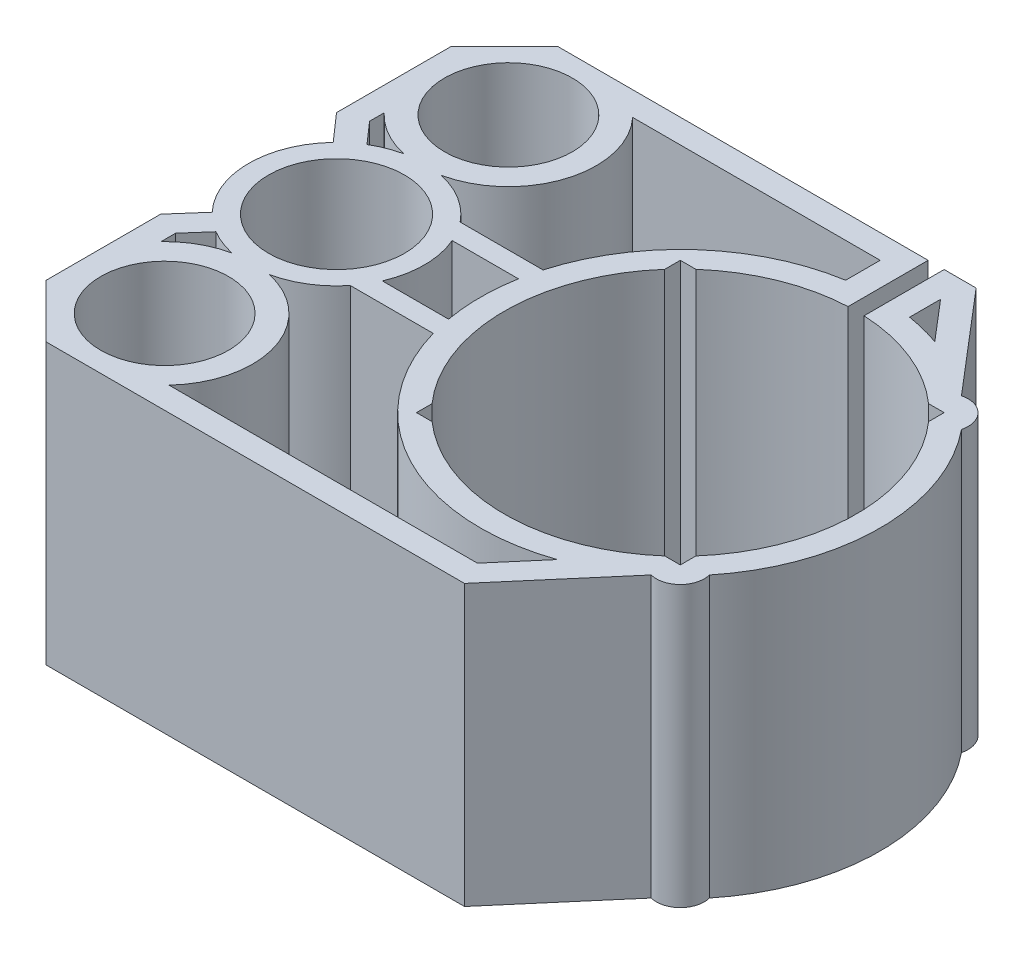
from build123d import *

# Parameters (mm, degrees)
SKETCH1_R           = 8
SKETCH1_R_2         = 8.5
BOSS_EXTRUDE1_DEPTH = 35
BOSS_EXTRUDE3_DEPTH = 12
CUT_EXTRUDE1_DEPTH  = 14.407172
SKETCH7_R           = 8.5
BOSS_EXTRUDE4_DEPTH = 15
SKETCH7_3_R         = 5
CUT_EXTRUDE2_DEPTH  = 15
SKETCH7_4_R         = 6.165
CUT_EXTRUDE3_DEPTH  = 1.5
SKETCH7_5_R         = 1.425
CUT_EXTRUDE4_DEPTH  = 8


with BuildPart() as part:
    # Sketch1 → Boss-Extrude1 (new body)
    with BuildSketch(Plane(origin=(0, 0, 0), x_dir=(1, 0, 0), z_dir=(0, 1, 0))):
        with BuildLine():
            ThreePointArc((-50.982546594, 7.568285795), (-54, 0), (-50.982546594, -7.568285795))
            Line((-50.982546594, -7.568285795), (-54, -11))
            Line((-54, -11), (-54, -25.34082208))
            Line((-54, -25.34082208), (-47.34082208, -32))
            Line((-47.34082208, -32), (5, -32))
            Line((5, -32), (15.759494281, -19.407172386))
            ThreePointArc((15.759494281, -19.407172386), (18.621320344, -18.621320344), (19.407172386, -15.759494281))
            ThreePointArc((19.407172386, -15.759494281), (25, 0), (19.407172386, 15.759494281))
            ThreePointArc((19.407172386, 15.759494281), (18.621320344, 18.621320344), (15.759494281, 19.407172386))
            Line((15.759494281, 19.407172386), (5, 32))
            Line((5, 32), (1, 32))
            Line((1, 32), (1, 21.977260976))
            ThreePointArc((1, 21.977260976), (8.243992543, 20.396974946), (14.551632211, 16.5))
            Line((14.551632211, 16.5), (16.5, 16.5))
            Line((16.5, 16.5), (16.5, 14.551632211))
            ThreePointArc((16.5, 14.551632211), (22, 0), (16.5, -14.551632211))
            Line((16.5, -14.551632211), (16.5, -16.5))
            Line((16.5, -16.5), (14.551632211, -16.5))
            ThreePointArc((14.551632211, -16.5), (0, -22), (-14.551632211, -16.5))
            Line((-14.551632211, -16.5), (-16.5, -16.5))
            Line((-16.5, -16.5), (-16.5, -14.551632211))
            ThreePointArc((-16.5, -14.551632211), (-22, 0), (-16.5, 14.551632211))
            Line((-16.5, 14.551632211), (-16.5, 16.5))
            Line((-16.5, 16.5), (-14.551632211, 16.5))
            ThreePointArc((-14.551632211, 16.5), (-8.243992543, 20.396974946), (-1, 21.977260976))
            Line((-1, 21.977260976), (-1, 32))
            Line((-1, 32), (-47.34082208, 32))
            Line((-47.34082208, 32), (-54, 25.34082208))
            Line((-54, 25.34082208), (-54, 11))
            Line((-54, 11), (-50.982546594, 7.568285795))
        make_face()
        with BuildLine():
            ThreePointArc((-48.638105805, -9.445197877), (-47.038026147, -10.232025451), (-45.331844763, -10.75))
            ThreePointArc((-45.331844763, -10.75), (-48.408051309, -11.921222362), (-51, -13.950165565))
            Line((-51, -13.950165565), (-51, -12.131352314))
            Line((-51, -12.131352314), (-48.638105805, -9.445197877))
        make_face(mode=Mode.SUBTRACT)
        with Locations((-43, -21.5)):
            Circle(SKETCH1_R, mode=Mode.SUBTRACT)
        with BuildLine():
            ThreePointArc((-34.95326153, -29), (-32.502649264, -18.212808567), (-40.668155237, -10.75))
            ThreePointArc((-40.668155237, -10.75), (-37.204464997, -9.349426401), (-34.409357086, -6.870287791))
            Line((-34.409357086, -6.870287791), (-24.037452978, -6.870287791))
            ThreePointArc((-24.037452978, -6.870287791), (-11.513133706, -22.191163833), (8.224630177, -23.60837687))
            Line((8.224630177, -23.60837687), (3.617949295, -29))
            Line((3.617949295, -29), (-34.95326153, -29))
        make_face(mode=Mode.SUBTRACT)
        with Locations((-43, 0)):
            Circle(SKETCH1_R_2, mode=Mode.SUBTRACT)
        with BuildLine():
            ThreePointArc((-45.331844763, 10.75), (-47.038026147, 10.232025451), (-48.638105805, 9.445197877))
            Line((-48.638105805, 9.445197877), (-51, 12.131352314))
            Line((-51, 12.131352314), (-51, 13.950165565))
            ThreePointArc((-51, 13.950165565), (-48.408051309, 11.921222362), (-45.331844763, 10.75))
        make_face(mode=Mode.SUBTRACT)
        with BuildLine():
            ThreePointArc((-32.905418056, -4.370287791), (-32, 0), (-32.905418056, 4.370287791))
            Line((-32.905418056, 4.370287791), (-24.615047931, 4.370287791))
            ThreePointArc((-24.615047931, 4.370287791), (-25, 0), (-24.615047931, -4.370287791))
            Line((-24.615047931, -4.370287791), (-32.905418056, -4.370287791))
        make_face(mode=Mode.SUBTRACT)
        with Locations((-43, 21.5)):
            Circle(SKETCH1_R, mode=Mode.SUBTRACT)
        with BuildLine():
            ThreePointArc((-34.409357086, 6.870287791), (-37.204464997, 9.349426401), (-40.668155237, 10.75))
            ThreePointArc((-40.668155237, 10.75), (-32.502649264, 18.212808567), (-34.95326153, 29))
            Line((-34.95326153, 29), (-4, 29))
            Line((-4, 29), (-4, 24.677925359))
            ThreePointArc((-4, 24.677925359), (-16.607308069, 18.68682206), (-24.037452978, 6.870287791))
            Line((-24.037452978, 6.870287791), (-34.409357086, 6.870287791))
        make_face(mode=Mode.SUBTRACT)
        with BuildLine():
            ThreePointArc((8.223751321, 23.608683026), (6.135213434, 24.235493725), (4, 24.677925359))
            Line((4, 24.677925359), (4, 28.552128404))
            Line((4, 28.552128404), (8.223751321, 23.608683026))
        make_face(mode=Mode.SUBTRACT)
    extrude(amount=BOSS_EXTRUDE1_DEPTH)

    # Sketch6 → Boss-Extrude3 (add)
    with BuildSketch(Plane(origin=(0, 23.5, 0), x_dir=(0, 0, -1), z_dir=(0, -1, 0))):
        Polygon((30.717367885, 3.963704263), (22.785433959, 3.963704263), (22.785433959, 10.604126234), align=None)
    extrude(amount=BOSS_EXTRUDE3_DEPTH)

    # Sketch3 → Cut-Extrude1 (cut)
    with BuildSketch(Plane.ZY.offset(-19.407172386)):
        with BuildLine():
            ThreePointArc((-23, 17.5), (-24.171572875, 20.328427125), (-27, 21.5))
            Line((-27, 21.5), (-27, 13.5))
            ThreePointArc((-27, 13.5), (-24.171572875, 14.671572875), (-23, 17.5))
        make_face()
        with BuildLine():
            Line((-27, 13.5), (-27, 21.5))
            ThreePointArc((-27, 21.5), (-31, 17.5), (-27, 13.5))
        make_face()
        with BuildLine():
            Line((-27, 21.5), (-32, 21.5))
            Line((-32, 21.5), (-32, 13.5))
            Line((-32, 13.5), (-27, 13.5))
            ThreePointArc((-27, 13.5), (-31, 17.5), (-27, 21.5))
        make_face()
    extrude(amount=CUT_EXTRUDE1_DEPTH, mode=Mode.SUBTRACT)

    # Sketch7 → Boss-Extrude4 (add)
    with BuildSketch(Plane.XZ):
        with Locations((-43, 0)):
            Circle(SKETCH7_R)
    extrude(amount=-BOSS_EXTRUDE4_DEPTH)

    # Sketch7_3 → Cut-Extrude2 (cut)
    with BuildSketch(Plane.XZ):
        with Locations((-43, 0)):
            Circle(SKETCH7_3_R)
    extrude(amount=-CUT_EXTRUDE2_DEPTH, mode=Mode.SUBTRACT)

    # Sketch7_4 → Cut-Extrude3 (cut)
    with BuildSketch(Plane.XZ):
        with Locations((-43, 0)):
            Circle(SKETCH7_4_R)
    extrude(amount=-CUT_EXTRUDE3_DEPTH, mode=Mode.SUBTRACT)

    # Sketch7_5 → Cut-Extrude4 (cut)
    with BuildSketch(Plane.XZ):
        with Locations((-48.64603005, -5.667657777)):
            Circle(SKETCH7_5_R)
        with Locations((-48.656854249, 5.656854249)):
            Circle(SKETCH7_5_R)
        with Locations((-37.332342223, 5.667678449)):
            Circle(SKETCH7_5_R)
        with Locations((-37.321518023, -5.656833577)):
            Circle(SKETCH7_5_R)
    extrude(amount=-CUT_EXTRUDE4_DEPTH, mode=Mode.SUBTRACT)


solid = part.part
